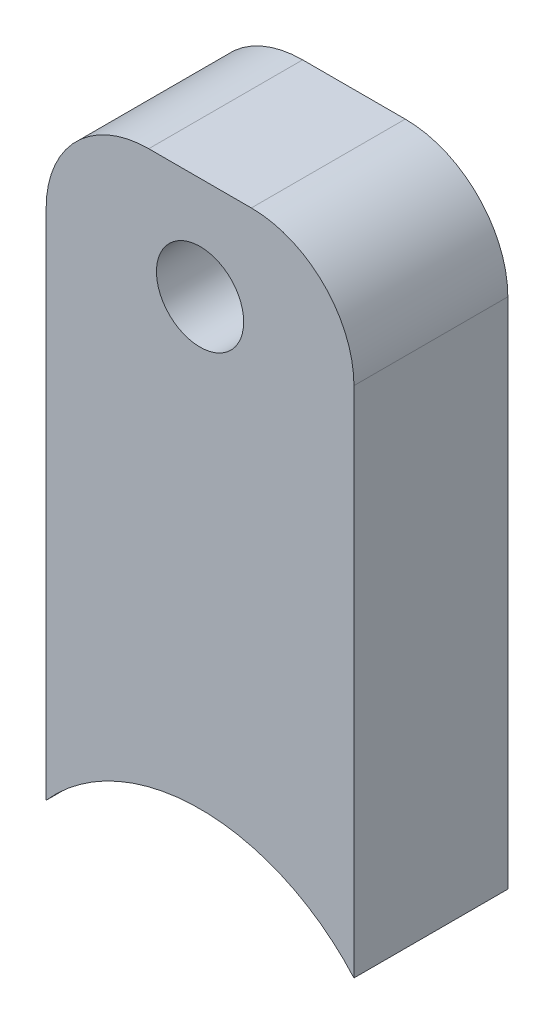
from build123d import *

# Parameters (mm, degrees)
BOSS_EXTRU_1_DEPTH = 15
TROU_TARAUD_M101_D = 8.5
CONG_1_R           = 10


with BuildPart() as part:
    # Esquisse1 → Boss.-Extru.1 (new body)
    with BuildSketch(Plane.XY):
        with BuildLine():
            Line((0, 0), (0, 60))
            Line((0, 60), (30, 60))
            Line((30, 60), (30, 0))
            ThreePointArc((30, 0), (15, 6.771243445), (0, 0))
        make_face()
    extrude(amount=BOSS_EXTRU_1_DEPTH)

    # Trou taraudé M101 (through all)
    with Locations(Plane.XY.offset(15)):
        with Locations((15, 50)):
            Hole(TROU_TARAUD_M101_D / 2)

    # Congé1
    cong_1_edges = [part.edges().sort_by_distance(p)[0] for p in [
        (0, 60, 7.5),
        (30, 60, 7.5),
    ]]
    fillet(cong_1_edges, radius=CONG_1_R)


solid = part.part
